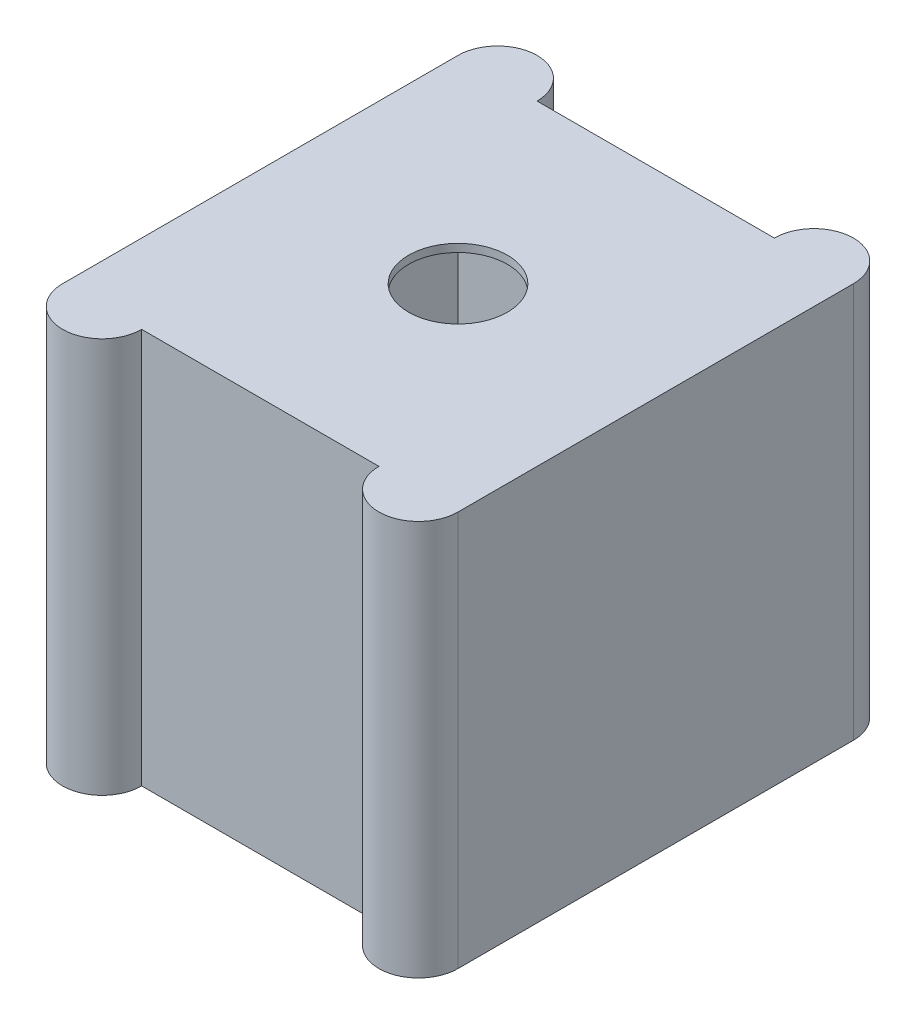
from build123d import *

# Parameters (mm, degrees)
SKETCH1_R           = 12.5
BOSS_EXTRUDE1_DEPTH = 100
SKETCH2_W           = 96
SKETCH2_H           = 96
CUT_EXTRUDE1_DEPTH  = 150


with BuildPart() as part:
    # Sketch1 → Boss-Extrude1 (new body)
    with BuildSketch(Plane(origin=(0, 0, 0), x_dir=(1, 0, 0), z_dir=(0, 1, 0))):
        with BuildLine():
            Line((-30, 50), (30, 50))
            ThreePointArc((30, 50), (40, 60), (50, 50))
            Line((50, 50), (50, -50))
            ThreePointArc((50, -50), (40, -60), (30, -50))
            Line((30, -50), (-30, -50))
            ThreePointArc((-30, -50), (-40, -60), (-50, -50))
            Line((-50, -50), (-50, 50))
            ThreePointArc((-50, 50), (-40, 60), (-30, 50))
        make_face()
        Circle(SKETCH1_R, mode=Mode.SUBTRACT)
    extrude(amount=BOSS_EXTRUDE1_DEPTH)

    # Sketch2 → Cut-Extrude1 (cut)
    with BuildSketch(Plane(origin=(0, 98, 0), x_dir=(1, 0, 0), z_dir=(0, 1, 0))):
        Rectangle(SKETCH2_W, SKETCH2_H)
    extrude(amount=-CUT_EXTRUDE1_DEPTH, mode=Mode.SUBTRACT)


solid = part.part
